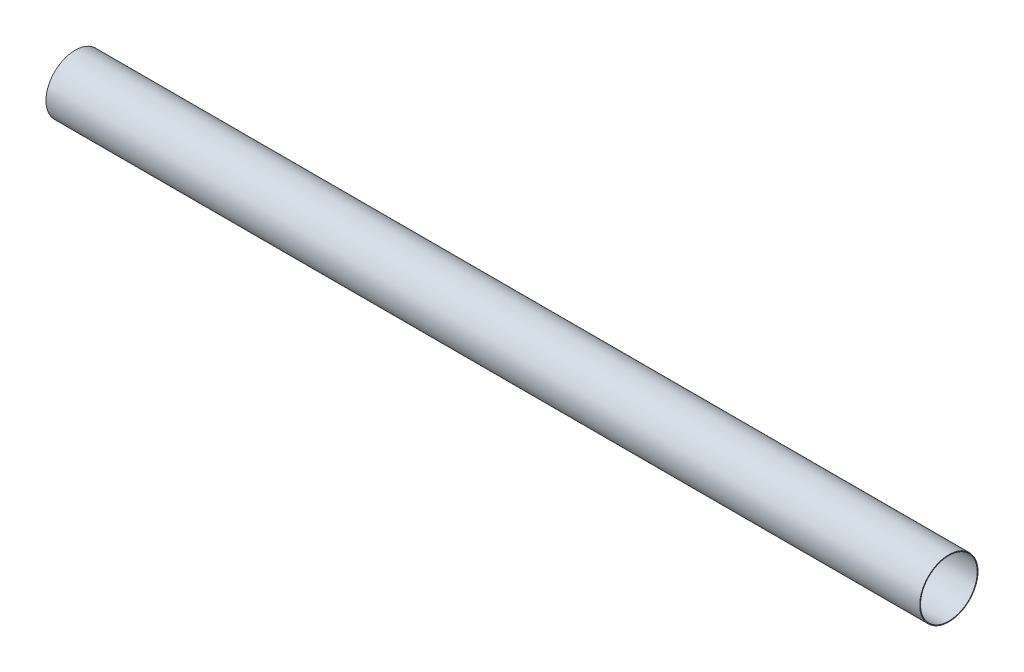
from build123d import *

# Parameters (mm, degrees)
SKETCH1_R           = 152.4
SKETCH1_R_2         = 148.59
BOSS_EXTRUDE1_DEPTH = 4572


with BuildPart() as part:
    # Sketch1 → Boss-Extrude1 (new body)
    with BuildSketch(Plane(origin=(0, 0, 0), x_dir=(0, 0, -1), z_dir=(1, 0, 0))):
        Circle(SKETCH1_R)
        Circle(SKETCH1_R_2, mode=Mode.SUBTRACT)
    extrude(amount=BOSS_EXTRUDE1_DEPTH)


solid = part.part
